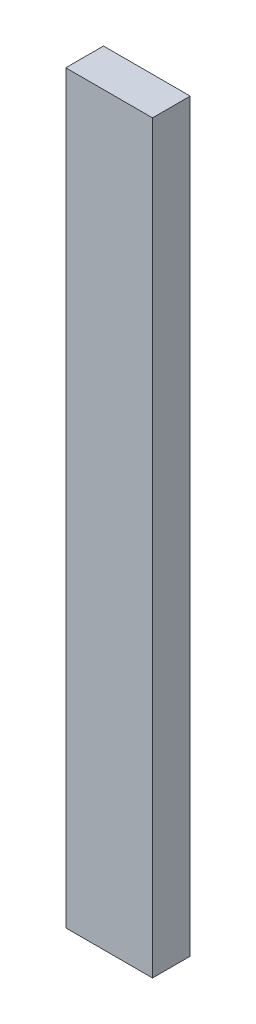
from build123d import *

# Parameters (mm, degrees)
SKETCH1_W           = 46
SKETCH1_H           = 20
BOSS_EXTRUDE1_DEPTH = 395


with BuildPart() as part:
    # Sketch1 → Boss-Extrude1 (new body)
    with BuildSketch(Plane(origin=(0, 0, 0), x_dir=(1, 0, 0), z_dir=(0, 1, 0))):
        Rectangle(SKETCH1_W, SKETCH1_H)
    extrude(amount=BOSS_EXTRUDE1_DEPTH)


solid = part.part
